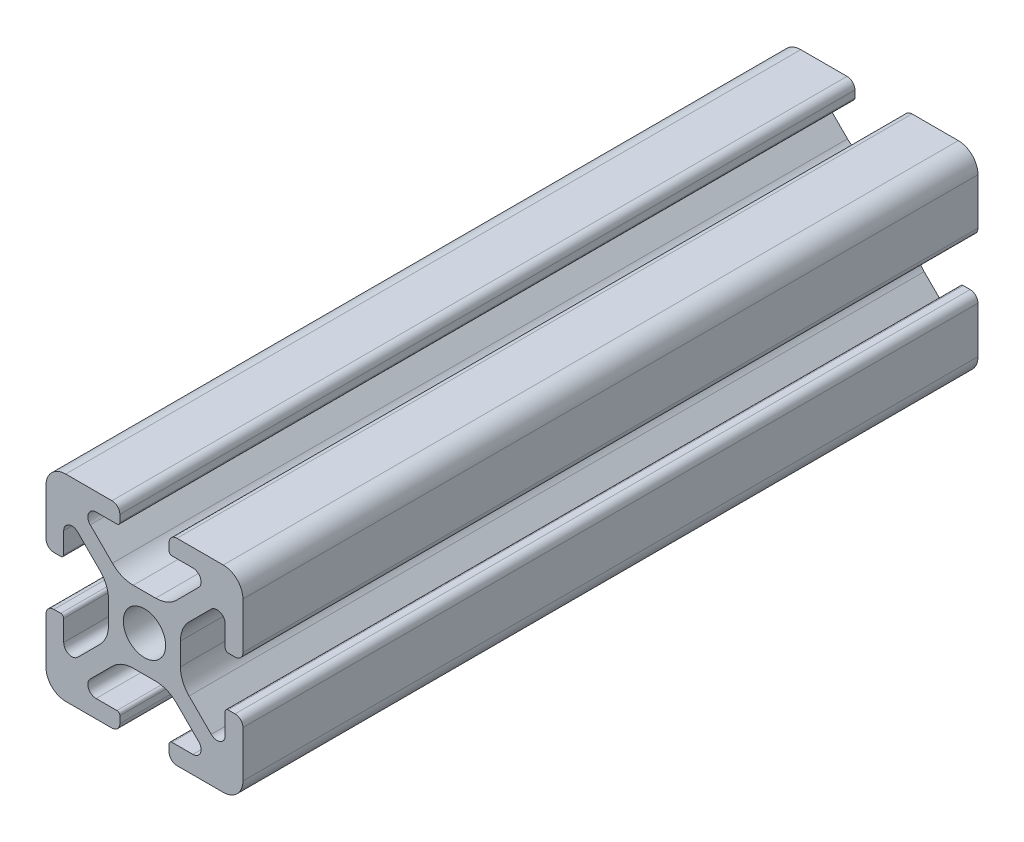
from build123d import *

# Parameters (mm, degrees)
SKETCH4_W              = 20
SKETCH4_H              = 20
BODY_DEPTH             = 74.65
SKETCH16_OUTSIDE_W     = 37.966
SKETCH16_OUTSIDE_H     = 37.966
SKETCH16_OUTSIDE_R     = 2.15
CUT_PROFILE_DEPTH      = 26
CUT_PROFILE_DEPTH_BACK = 50.65


with BuildPart() as part:
    # Sketch4 → Body (new body)
    with BuildSketch(Plane.XY.offset(25)):
        Rectangle(SKETCH4_W, SKETCH4_H)
    extrude(amount=-BODY_DEPTH)

    # Sketch16 outside → Cut-Profile (cut, two sides)
    with BuildSketch(Plane.XY) as cut_profile_sk:
        Rectangle(SKETCH16_OUTSIDE_W, SKETCH16_OUTSIDE_H)
        with BuildLine():
            Line((4.917588389, -8.199999991), (2.799999989, -8.199999991))
            ThreePointArc((2.799999989, -8.199999991), (2.587867955, -8.287867957), (2.499999989, -8.499999991))
            Line((2.499999989, -8.499999991), (2.499999989, -9.199999991))
            ThreePointArc((2.499999989, -9.199999991), (2.734314564, -9.765685416), (3.299999989, -9.999999991))
            Line((3.299999989, -9.999999991), (7.999999989, -9.999999991))
            ThreePointArc((7.999999989, -9.999999991), (9.414213552, -9.414213554), (9.999999989, -7.999999991))
            Line((9.999999989, -7.999999991), (9.999999989, -3.299999991))
            ThreePointArc((9.999999989, -3.299999991), (9.765685414, -2.734314566), (9.199999989, -2.499999991))
            Line((9.199999989, -2.499999991), (8.499999989, -2.499999991))
            ThreePointArc((8.499999989, -2.499999991), (8.287867955, -2.587867957), (8.199999989, -2.799999991))
            Line((8.199999989, -2.799999991), (8.199999989, -4.917588391))
            ThreePointArc((8.199999989, -4.917588391), (7.686138511, -5.686636441), (6.778984485, -5.506192286))
            Line((6.778984485, -5.506192286), (4.528679645, -3.255887446))
            ThreePointArc((4.528679645, -3.255887446), (3.878361392, -2.282617401), (3.64999999, -1.134567106))
            Line((3.64999999, -1.134567106), (3.64999999, 1.134567104))
            ThreePointArc((3.64999999, 1.134567104), (3.878361393, 2.282617402), (4.528679647, 3.255887448))
            Line((4.528679647, 3.255887448), (6.778984487, 5.506192288))
            ThreePointArc((6.778984487, 5.506192288), (7.686138506, 5.686636442), (8.199999981, 4.917588398))
            Line((8.199999981, 4.917588398), (8.199999981, 2.799999998))
            ThreePointArc((8.199999981, 2.799999998), (8.287867946, 2.587867964), (8.499999981, 2.499999998))
            Line((8.499999981, 2.499999998), (9.199999981, 2.499999998))
            ThreePointArc((9.199999981, 2.499999998), (9.765685406, 2.734314573), (9.999999981, 3.299999998))
            Line((9.999999981, 3.299999998), (9.999999981, 7.999999998))
            ThreePointArc((9.999999981, 7.999999998), (9.414213543, 9.41421356), (7.999999981, 9.999999998))
            Line((7.999999981, 9.999999998), (3.299999981, 9.999999998))
            ThreePointArc((3.299999981, 9.999999998), (2.734314556, 9.765685423), (2.499999981, 9.199999998))
            Line((2.499999981, 9.199999998), (2.499999981, 8.499999998))
            ThreePointArc((2.499999981, 8.499999998), (2.587867946, 8.287867964), (2.799999981, 8.199999998))
            Line((2.799999981, 8.199999998), (4.917588381, 8.199999998))
            ThreePointArc((4.917588381, 8.199999998), (5.68663643, 7.68613852), (5.506192275, 6.778984494))
            Line((5.506192275, 6.778984494), (3.255887435, 4.528679654))
            ThreePointArc((3.255887435, 4.528679654), (2.28261739, 3.878361401), (1.134567095, 3.649999999))
            Line((1.134567095, 3.649999999), (-1.134567115, 3.649999999))
            ThreePointArc((-1.134567115, 3.649999999), (-2.282617412, 3.878361401), (-3.255887459, 4.528679655))
            Line((-3.255887459, 4.528679655), (-5.506192299, 6.778984495))
            ThreePointArc((-5.506192299, 6.778984495), (-5.686636452, 7.686138515), (-4.917588409, 8.199999989))
            Line((-4.917588409, 8.199999989), (-2.800000009, 8.199999989))
            ThreePointArc((-2.800000009, 8.199999989), (-2.587867974, 8.287867955), (-2.500000009, 8.499999989))
            Line((-2.500000009, 8.499999989), (-2.500000009, 9.199999989))
            ThreePointArc((-2.500000009, 9.199999989), (-2.734314584, 9.765685414), (-3.300000009, 9.999999989))
            Line((-3.300000009, 9.999999989), (-8.000000009, 9.999999989))
            ThreePointArc((-8.000000009, 9.999999989), (-9.414213571, 9.414213552), (-10.000000009, 7.999999989))
            Line((-10.000000009, 7.999999989), (-10.000000009, 3.299999989))
            ThreePointArc((-10.000000009, 3.299999989), (-9.765685434, 2.734314564), (-9.200000009, 2.499999989))
            Line((-9.200000009, 2.499999989), (-8.500000009, 2.499999989))
            ThreePointArc((-8.500000009, 2.499999989), (-8.287867974, 2.587867955), (-8.200000009, 2.799999989))
            Line((-8.200000009, 2.799999989), (-8.200000009, 4.917588389))
            ThreePointArc((-8.200000009, 4.917588389), (-7.686138531, 5.686636438), (-6.778984504, 5.506192284))
            Line((-6.778984504, 5.506192284), (-4.528679664, 3.255887444))
            ThreePointArc((-4.528679664, 3.255887444), (-3.878361412, 2.282617399), (-3.650000009, 1.134567104))
            Line((-3.650000009, 1.134567104), (-3.650000009, -1.134567106))
            ThreePointArc((-3.650000009, -1.134567106), (-3.878361412, -2.282617404), (-4.528679666, -3.25588745))
            Line((-4.528679666, -3.25588745), (-6.778984506, -5.50619229))
            ThreePointArc((-6.778984506, -5.50619229), (-7.686138526, -5.686636444), (-8.2, -4.9175884))
            Line((-8.2, -4.9175884), (-8.2, -2.8))
            ThreePointArc((-8.2, -2.8), (-8.287867966, -2.587867966), (-8.5, -2.5))
            Line((-8.5, -2.5), (-9.2, -2.5))
            ThreePointArc((-9.2, -2.5), (-9.765685425, -2.734314575), (-10, -3.3))
            Line((-10, -3.3), (-10, -8))
            ThreePointArc((-10, -8), (-9.414213562, -9.414213562), (-8, -10))
            Line((-8, -10), (-3.3, -10))
            ThreePointArc((-3.3, -10), (-2.734314575, -9.765685425), (-2.5, -9.2))
            Line((-2.5, -9.2), (-2.5, -8.5))
            ThreePointArc((-2.5, -8.5), (-2.587867966, -8.287867966), (-2.8, -8.2))
            Line((-2.8, -8.2), (-4.9175884, -8.2))
            ThreePointArc((-4.9175884, -8.2), (-5.686636449, -7.686138522), (-5.506192294, -6.778984496))
            Line((-5.506192294, -6.778984496), (-3.255887454, -4.528679656))
            ThreePointArc((-3.255887454, -4.528679656), (-2.282617409, -3.878361403), (-1.134567114, -3.650000001))
            Line((-1.134567114, -3.650000001), (1.134567096, -3.650000001))
            ThreePointArc((1.134567096, -3.650000001), (2.282617393, -3.878361403), (3.255887439, -4.528679657))
            Line((3.255887439, -4.528679657), (5.506192279, -6.778984497))
            ThreePointArc((5.506192279, -6.778984497), (5.686636433, -7.686138517), (4.917588389, -8.199999991))
        make_face(mode=Mode.SUBTRACT)
        Circle(SKETCH16_OUTSIDE_R)
    extrude(amount=CUT_PROFILE_DEPTH, mode=Mode.SUBTRACT)
    extrude(cut_profile_sk.sketch, amount=-CUT_PROFILE_DEPTH_BACK, mode=Mode.SUBTRACT)


solid = part.part
